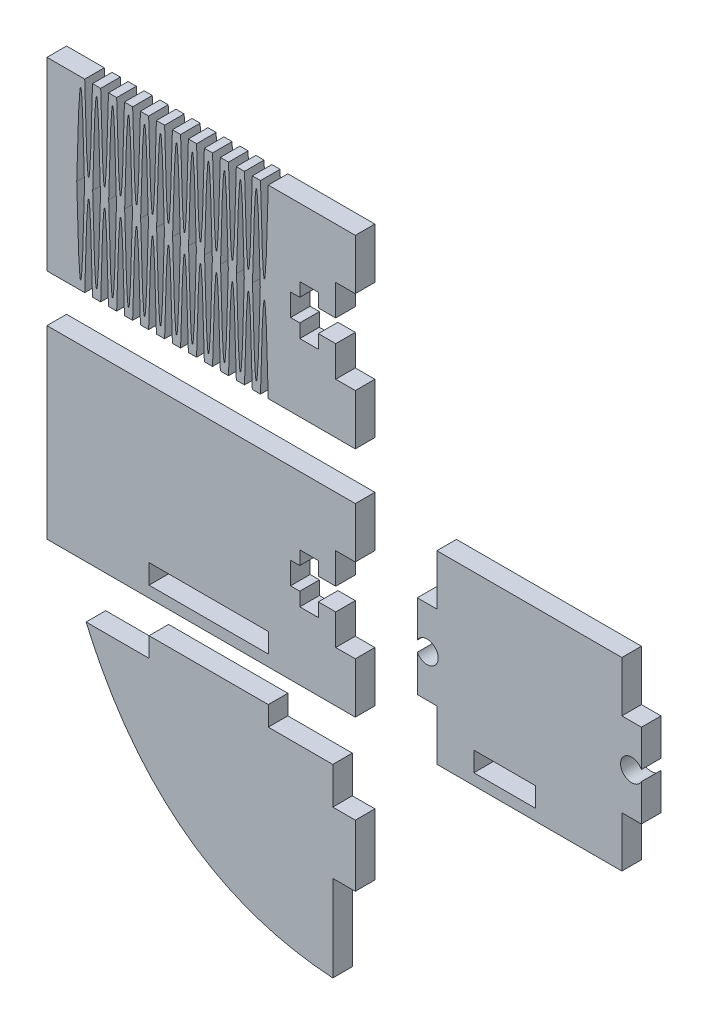
from build123d import *

# Parameters (mm, degrees)
SKETCH1_W             = 10
SKETCH1_H             = 3.175
BOSS_EXTRUDE3_DEPTH   = 3.175
SKETCH1_W_2           = 19.338503776
BOSS_EXTRUDE3_2_DEPTH = 3.175
BOSS_EXTRUDE3_3_DEPTH = 3.175
BOSS_EXTRUDE3_4_DEPTH = 3.175


with BuildPart() as part:
    # Sketch1 → Boss-Extrude3 (new body)
    with BuildSketch(Plane.XY):
        with BuildLine():
            Line((-33.68050161, 39.580766243), (-36.85550161, 39.580766243))
            Line((-36.85550161, 39.580766243), (-36.85550161, 33.629202304))
            ThreePointArc((-36.85550161, 33.629202304), (-33.46800161, 32.780766243), (-36.85550161, 31.932330182))
            Line((-36.85550161, 31.932330182), (-36.85550161, 25.980766243))
            Line((-36.85550161, 25.980766243), (-33.68050161, 25.980766243))
            Line((-33.68050161, 25.980766243), (-33.68050161, 17.780766243))
            Line((-33.68050161, 17.780766243), (-3.68050161, 17.780766243))
            Line((-3.68050161, 17.780766243), (-3.68050161, 25.980766243))
            Line((-3.68050161, 25.980766243), (-0.50550161, 25.980766243))
            Line((-0.50550161, 25.980766243), (-0.50550161, 31.932330182))
            ThreePointArc((-0.50550161, 31.932330182), (-3.89300161, 32.780766243), (-0.50550161, 33.629202304))
            Line((-0.50550161, 33.629202304), (-0.50550161, 39.580766243))
            Line((-0.50550161, 39.580766243), (-3.68050161, 39.580766243))
            Line((-3.68050161, 39.580766243), (-3.68050161, 47.780766243))
            Line((-3.68050161, 47.780766243), (-33.68050161, 47.780766243))
            Line((-33.68050161, 47.780766243), (-33.68050161, 39.580766243))
        make_face()
        with Locations((-22.68050161, 21.182701237)):
            Rectangle(SKETCH1_W, SKETCH1_H, mode=Mode.SUBTRACT)
    extrude(amount=BOSS_EXTRUDE3_DEPTH)


with BuildPart() as body_2:
    # Sketch1 → Boss-Extrude3 2 (new body)
    with BuildSketch(Plane.XY):
        Polygon((-96.911258203, 47.780766243), (-46.911258203, 47.780766243), (-46.911258203, 39.580766243), (-50.086258203, 39.580766243), (-50.086258203, 34.580766243), (-52.911258203, 34.580766243), (-52.911258203, 36.780766243), (-55.911258203, 36.780766243), (-55.911258203, 34.580766243), (-57.411258203, 34.580766243), (-57.411258203, 30.980766243), (-55.911258203, 30.980766243), (-55.911258203, 28.780766243), (-52.911258203, 28.780766243), (-52.911258203, 30.980766243), (-50.086258203, 30.980766243), (-50.086258203, 25.980766243), (-46.911258203, 25.980766243), (-46.911258203, 17.780766243), (-96.911258203, 17.780766243), align=None)
        with Locations((-70.694345596, 21.182701237)):
            Rectangle(SKETCH1_W_2, SKETCH1_H, mode=Mode.SUBTRACT)
    extrude(amount=BOSS_EXTRUDE3_2_DEPTH)


with BuildPart() as body_3:
    # Sketch1 → Boss-Extrude3 3 (new body)
    with BuildSketch(Plane.XY):
        with BuildLine():
            Line((-50.564988155, 9.325788887), (-61.025093708, 9.325788887))
            Line((-61.025093708, 9.325788887), (-61.025093708, 12.500788887))
            Line((-61.025093708, 12.500788887), (-80.363597484, 12.500788887))
            Line((-80.363597484, 12.500788887), (-80.363597484, 9.325788887))
            Line((-80.363597484, 9.325788887), (-90.564988155, 9.325788887))
            add(Edge.make_bspline(
                [(-50.564988155, -20.674211113), (-78.351175561, -18.870925546), (-90.564988155, 9.325788887)],
                knots=[0, 0, 0, 1, 1, 1], degree=2))
            Line((-50.564988155, -20.674211113), (-50.564988155, -6.674211113))
            Line((-50.564988155, -6.674211113), (-46.911258203, -6.674211113))
            Line((-46.911258203, -6.674211113), (-46.911258203, 3.325788887))
            Line((-46.911258203, 3.325788887), (-50.564988155, 3.325788887))
            Line((-50.564988155, 3.325788887), (-50.564988155, 9.325788887))
        make_face()
    extrude(amount=BOSS_EXTRUDE3_3_DEPTH)


with BuildPart() as body_4:
    # Sketch1 → Boss-Extrude3 4 (new body)
    with BuildSketch(Plane.XY):
        with BuildLine():
            Line((-46.911258203, 77.257267205), (-46.911258203, 85.457267205))
            Line((-46.911258203, 85.457267205), (-61.025093708, 85.457267205))
            add(Edge.make_bspline(
                [(-61.025093708, 85.457267205), (-61.655906271, 58.402357683), (-62.286718834, 85.457267205)],
                knots=[0, 0, 0, 1, 1, 1], degree=2))
            Line((-62.286718834, 85.457267205), (-63.616268409, 85.457267205))
            add(Edge.make_bspline(
                [(-64.877893535, 85.457267205), (-64.247080972, 58.402357683), (-63.616268409, 85.457267205)],
                knots=[0, 0, 0, 1, 1, 1], degree=2))
            Line((-64.877893535, 85.457267205), (-66.207510978, 85.457267205))
            add(Edge.make_bspline(
                [(-66.207510978, 85.457267205), (-66.838212082, 58.40223111), (-67.469136108, 85.457496903)],
                knots=[0, 0, 0, 1, 1, 1], degree=2))
            Line((-67.469136108, 85.457496903), (-68.798685682, 85.457482171))
            add(Edge.make_bspline(
                [(-70.060310806, 85.457246765), (-69.429365141, 58.402225249), (-68.798685682, 85.457482171)],
                knots=[0, 0, 0, 1, 1, 1], degree=2))
            Line((-70.060310806, 85.457246765), (-71.390030732, 85.457246765))
            add(Edge.make_bspline(
                [(-71.390030732, 85.457246765), (-72.020965708, 58.402340098), (-72.651655859, 85.457252473)],
                knots=[0, 0, 0, 1, 1, 1], degree=2))
            Line((-72.651655859, 85.457252473), (-73.981205433, 85.457267205))
            add(Edge.make_bspline(
                [(-75.24283056, 85.457267205), (-74.612140143, 58.402345959), (-73.981205433, 85.457267205)],
                knots=[0, 0, 0, 1, 1, 1], degree=2))
            Line((-75.24283056, 85.457267205), (-76.572448003, 85.457267205))
            add(Edge.make_bspline(
                [(-76.572448003, 85.457267205), (-77.203260566, 58.402357683), (-77.83407313, 85.457267205)],
                knots=[0, 0, 0, 1, 1, 1], degree=2))
            Line((-77.83407313, 85.457267205), (-79.163622704, 85.457267205))
            add(Edge.make_bspline(
                [(-80.425247831, 85.457267205), (-79.794435267, 58.402357683), (-79.163622704, 85.457267205)],
                knots=[0, 0, 0, 1, 1, 1], degree=2))
            Line((-80.425247831, 85.457267205), (-81.755225929, 85.457267205))
            add(Edge.make_bspline(
                [(-81.755225929, 85.457267205), (-82.386038492, 58.402357683), (-83.016851056, 85.457267205)],
                knots=[0, 0, 0, 1, 1, 1], degree=2))
            Line((-83.016851056, 85.457267205), (-84.34640063, 85.457267205))
            add(Edge.make_bspline(
                [(-85.608025757, 85.457267205), (-84.977213193, 58.402357683), (-84.34640063, 85.457267205)],
                knots=[0, 0, 0, 1, 1, 1], degree=2))
            Line((-85.608025757, 85.457267205), (-86.9376432, 85.457267205))
            add(Edge.make_bspline(
                [(-86.9376432, 85.457267205), (-87.568333617, 58.402345959), (-88.199268326, 85.457267205)],
                knots=[0, 0, 0, 1, 1, 1], degree=2))
            Line((-88.199268326, 85.457267205), (-89.528817901, 85.457252473))
            add(Edge.make_bspline(
                [(-90.790443027, 85.457246765), (-90.159508052, 58.402340098), (-89.528817901, 85.457252473)],
                knots=[0, 0, 0, 1, 1, 1], degree=2))
            Line((-90.790443027, 85.457246765), (-96.911258203, 85.457267205))
            Line((-96.911258203, 85.457267205), (-96.911258203, 55.457267205))
            Line((-96.911258203, 55.457267205), (-90.79030729, 55.457246765))
            add(Edge.make_bspline(
                [(-90.79030729, 55.457246765), (-90.159617139, 82.512159141), (-89.528682163, 55.457252473)],
                knots=[0, 0, 0, 1, 1, 1], degree=2))
            Line((-89.528682163, 55.457252473), (-88.199132589, 55.457267205))
            add(Edge.make_bspline(
                [(-86.937507462, 55.457267205), (-87.568442172, 82.512165003), (-88.199132589, 55.457267205)],
                knots=[0, 0, 0, 1, 1, 1], degree=2))
            Line((-86.937507462, 55.457267205), (-85.608025757, 55.457267205))
            add(Edge.make_bspline(
                [(-85.608025757, 55.457267205), (-84.977213193, 82.512176727), (-84.34640063, 55.457267205)],
                knots=[0, 0, 0, 1, 1, 1], degree=2))
            Line((-84.34640063, 55.457267205), (-83.016851056, 55.457267205))
            add(Edge.make_bspline(
                [(-81.755225929, 55.457267205), (-82.386038492, 82.512176727), (-83.016851056, 55.457267205)],
                knots=[0, 0, 0, 1, 1, 1], degree=2))
            Line((-81.755225929, 55.457267205), (-80.425247831, 55.457267205))
            add(Edge.make_bspline(
                [(-80.425247831, 55.457267205), (-79.794435267, 82.512176727), (-79.163622704, 55.457267205)],
                knots=[0, 0, 0, 1, 1, 1], degree=2))
            Line((-79.163622704, 55.457267205), (-77.83407313, 55.457267205))
            add(Edge.make_bspline(
                [(-76.572448003, 55.457267205), (-77.203260566, 82.512176727), (-77.83407313, 55.457267205)],
                knots=[0, 0, 0, 1, 1, 1], degree=2))
            Line((-76.572448003, 55.457267205), (-75.242966297, 55.457267205))
            add(Edge.make_bspline(
                [(-75.242966297, 55.457267205), (-74.612031588, 82.512165003), (-73.981341171, 55.457267205)],
                knots=[0, 0, 0, 1, 1, 1], degree=2))
            Line((-73.981341171, 55.457267205), (-72.651791596, 55.457252473))
            add(Edge.make_bspline(
                [(-71.39016647, 55.457246765), (-72.020856621, 82.512159141), (-72.651791596, 55.457252473)],
                knots=[0, 0, 0, 1, 1, 1], degree=2))
            Line((-71.39016647, 55.457246765), (-70.060175069, 55.457246765))
            add(Edge.make_bspline(
                [(-70.060175069, 55.457246765), (-69.429484917, 82.512159141), (-68.798549942, 55.457252473)],
                knots=[0, 0, 0, 1, 1, 1], degree=2))
            Line((-68.798549942, 55.457252473), (-67.469000368, 55.457267205))
            add(Edge.make_bspline(
                [(-66.207375241, 55.457267205), (-66.838309951, 82.512165003), (-67.469000368, 55.457267205)],
                knots=[0, 0, 0, 1, 1, 1], degree=2))
            Line((-66.207375241, 55.457267205), (-64.877893535, 55.457267205))
            add(Edge.make_bspline(
                [(-64.877893535, 55.457267205), (-64.247080972, 82.512176727), (-63.616268409, 55.457267205)],
                knots=[0, 0, 0, 1, 1, 1], degree=2))
            Line((-63.616268409, 55.457267205), (-62.286718834, 55.457267205))
            add(Edge.make_bspline(
                [(-61.025093708, 55.457267205), (-61.655906271, 82.512176727), (-62.286718834, 55.457267205)],
                knots=[0, 0, 0, 1, 1, 1], degree=2))
            Line((-61.025093708, 55.457267205), (-46.911258203, 55.457267205))
            Line((-46.911258203, 55.457267205), (-46.911258203, 63.657267205))
            Line((-46.911258203, 63.657267205), (-50.086258203, 63.657267205))
            Line((-50.086258203, 63.657267205), (-50.086258203, 68.657267205))
            Line((-50.086258203, 68.657267205), (-52.911258203, 68.657267205))
            Line((-52.911258203, 68.657267205), (-52.911258203, 66.457267205))
            Line((-52.911258203, 66.457267205), (-55.911258203, 66.457267205))
            Line((-55.911258203, 66.457267205), (-55.911258203, 68.657267205))
            Line((-55.911258203, 68.657267205), (-57.411258203, 68.657267205))
            Line((-57.411258203, 68.657267205), (-57.411258203, 72.257267205))
            Line((-57.411258203, 72.257267205), (-55.911258203, 72.257267205))
            Line((-55.911258203, 72.257267205), (-55.911258203, 74.457267205))
            Line((-55.911258203, 74.457267205), (-52.911258203, 74.457267205))
            Line((-52.911258203, 74.457267205), (-52.911258203, 72.257267205))
            Line((-52.911258203, 72.257267205), (-50.086258203, 72.257267205))
            Line((-50.086258203, 72.257267205), (-50.086258203, 77.257267205))
            Line((-50.086258203, 77.257267205), (-46.911258203, 77.257267205))
        make_face()
        with BuildLine():
            Line((-63.582306185, 70.459898744), (-63.582306185, 70.454635666))
            add(Edge.make_bspline(
                [(-62.320681058, 70.457267205), (-62.951371186, 43.398410376), (-63.582306185, 70.454635666)],
                knots=[0, 0, 0, 1, 1, 1], degree=2))
            add(Edge.make_bspline(
                [(-62.320681058, 70.457267205), (-62.951371186, 97.516124034), (-63.582306185, 70.459898744)],
                knots=[0, 0, 0, 1, 1, 1], degree=2))
        make_face(mode=Mode.SUBTRACT)
        with BuildLine():
            Line((-64.911855759, 70.459898744), (-64.911855759, 70.454635666))
            add(Edge.make_bspline(
                [(-66.173480886, 70.457267205), (-65.542790758, 43.398410376), (-64.911855759, 70.454635666)],
                knots=[0, 0, 0, 1, 1, 1], degree=2))
            add(Edge.make_bspline(
                [(-66.173480886, 70.457267205), (-65.542790758, 97.516124034), (-64.911855759, 70.459898744)],
                knots=[0, 0, 0, 1, 1, 1], degree=2))
        make_face(mode=Mode.SUBTRACT)
        with BuildLine():
            Line((-68.764655563, 70.454618234), (-68.764655611, 70.459881312))
            add(Edge.make_bspline(
                [(-67.50303046, 70.457261189), (-68.133965447, 97.51611231), (-68.764655611, 70.459881312)],
                knots=[0, 0, 0, 1, 1, 1], degree=2))
            add(Edge.make_bspline(
                [(-67.50303046, 70.457261189), (-68.133475728, 43.398398654), (-68.764655563, 70.454618234)],
                knots=[0, 0, 0, 1, 1, 1], degree=2))
        make_face(mode=Mode.SUBTRACT)
        with BuildLine():
            Line((-70.094205137, 70.454606203), (-70.094205185, 70.45986928))
            add(Edge.make_bspline(
                [(-71.355830288, 70.457226325), (-70.72538502, 97.51608886), (-70.094205185, 70.45986928)],
                knots=[0, 0, 0, 1, 1, 1], degree=2))
            add(Edge.make_bspline(
                [(-71.355830288, 70.457226325), (-70.7248953, 43.398375204), (-70.094205137, 70.454606203)],
                knots=[0, 0, 0, 1, 1, 1], degree=2))
        make_face(mode=Mode.SUBTRACT)
        with BuildLine():
            Line((-73.947617215, 70.454623638), (-73.94761712, 70.459886715))
            add(Edge.make_bspline(
                [(-72.685992041, 70.457232343), (-73.316192449, 97.516100582), (-73.94761712, 70.459886715)],
                knots=[0, 0, 0, 1, 1, 1], degree=2))
            add(Edge.make_bspline(
                [(-72.685992041, 70.457232343), (-73.317171888, 43.398386933), (-73.947617215, 70.454623638)],
                knots=[0, 0, 0, 1, 1, 1], degree=2))
        make_face(mode=Mode.SUBTRACT)
        with BuildLine():
            Line((-75.27716679, 70.454647701), (-75.277166694, 70.459910778))
            add(Edge.make_bspline(
                [(-76.538791868, 70.457302072), (-75.907612021, 97.516147483), (-75.277166694, 70.459910778)],
                knots=[0, 0, 0, 1, 1, 1], degree=2))
            add(Edge.make_bspline(
                [(-76.538791868, 70.457302072), (-75.908591461, 43.398433833), (-75.27716679, 70.454647701)],
                knots=[0, 0, 0, 1, 1, 1], degree=2))
        make_face(mode=Mode.SUBTRACT)
        with BuildLine():
            Line((-79.129966593, 70.454699997), (-79.129966545, 70.459963075))
            add(Edge.make_bspline(
                [(-77.868341443, 70.457320119), (-78.49878671, 97.516182655), (-79.129966545, 70.459963075)],
                knots=[0, 0, 0, 1, 1, 1], degree=2))
            add(Edge.make_bspline(
                [(-77.868341443, 70.457320119), (-78.49927643, 43.398468999), (-79.129966593, 70.454699997)],
                knots=[0, 0, 0, 1, 1, 1], degree=2))
        make_face(mode=Mode.SUBTRACT)
        with BuildLine():
            Line((-80.459516167, 70.454712029), (-80.45951612, 70.459975106))
            add(Edge.make_bspline(
                [(-81.72114127, 70.457354984), (-81.090206283, 97.516206105), (-80.45951612, 70.459975106)],
                knots=[0, 0, 0, 1, 1, 1], degree=2))
            add(Edge.make_bspline(
                [(-81.72114127, 70.457354984), (-81.090696002, 43.398492449), (-80.459516167, 70.454712029)],
                knots=[0, 0, 0, 1, 1, 1], degree=2))
        make_face(mode=Mode.SUBTRACT)
        with BuildLine():
            Line((-84.312560817, 70.454712029), (-84.312560865, 70.459975106))
            add(Edge.make_bspline(
                [(-83.050935715, 70.457354984), (-83.681870702, 97.516206105), (-84.312560865, 70.459975106)],
                knots=[0, 0, 0, 1, 1, 1], degree=2))
            add(Edge.make_bspline(
                [(-83.050935715, 70.457354984), (-83.681380982, 43.398492449), (-84.312560817, 70.454712029)],
                knots=[0, 0, 0, 1, 1, 1], degree=2))
        make_face(mode=Mode.SUBTRACT)
        with BuildLine():
            Line((-85.642110392, 70.454699997), (-85.642110439, 70.459963075))
            add(Edge.make_bspline(
                [(-86.903735542, 70.457320119), (-86.273290274, 97.516182655), (-85.642110439, 70.459963075)],
                knots=[0, 0, 0, 1, 1, 1], degree=2))
            add(Edge.make_bspline(
                [(-86.903735542, 70.457320119), (-86.272800555, 43.398468999), (-85.642110392, 70.454699997)],
                knots=[0, 0, 0, 1, 1, 1], degree=2))
        make_face(mode=Mode.SUBTRACT)
        with BuildLine():
            Line((-89.494910195, 70.454647701), (-89.49491029, 70.459910778))
            add(Edge.make_bspline(
                [(-88.233285116, 70.457302072), (-88.864464963, 97.516147483), (-89.49491029, 70.459910778)],
                knots=[0, 0, 0, 1, 1, 1], degree=2))
            add(Edge.make_bspline(
                [(-88.233285116, 70.457302072), (-88.863485524, 43.398433833), (-89.494910195, 70.454647701)],
                knots=[0, 0, 0, 1, 1, 1], degree=2))
        make_face(mode=Mode.SUBTRACT)
        with BuildLine():
            Line((-90.824459769, 70.454623638), (-90.824459865, 70.459886715))
            add(Edge.make_bspline(
                [(-92.086084943, 70.457232343), (-91.455884536, 97.516100582), (-90.824459865, 70.459886715)],
                knots=[0, 0, 0, 1, 1, 1], degree=2))
            add(Edge.make_bspline(
                [(-92.086084943, 70.457232343), (-91.454905096, 43.398386933), (-90.824459769, 70.454623638)],
                knots=[0, 0, 0, 1, 1, 1], degree=2))
        make_face(mode=Mode.SUBTRACT)
    extrude(amount=BOSS_EXTRUDE3_4_DEPTH)


solid = Compound([part.part, body_2.part, body_3.part, body_4.part])
